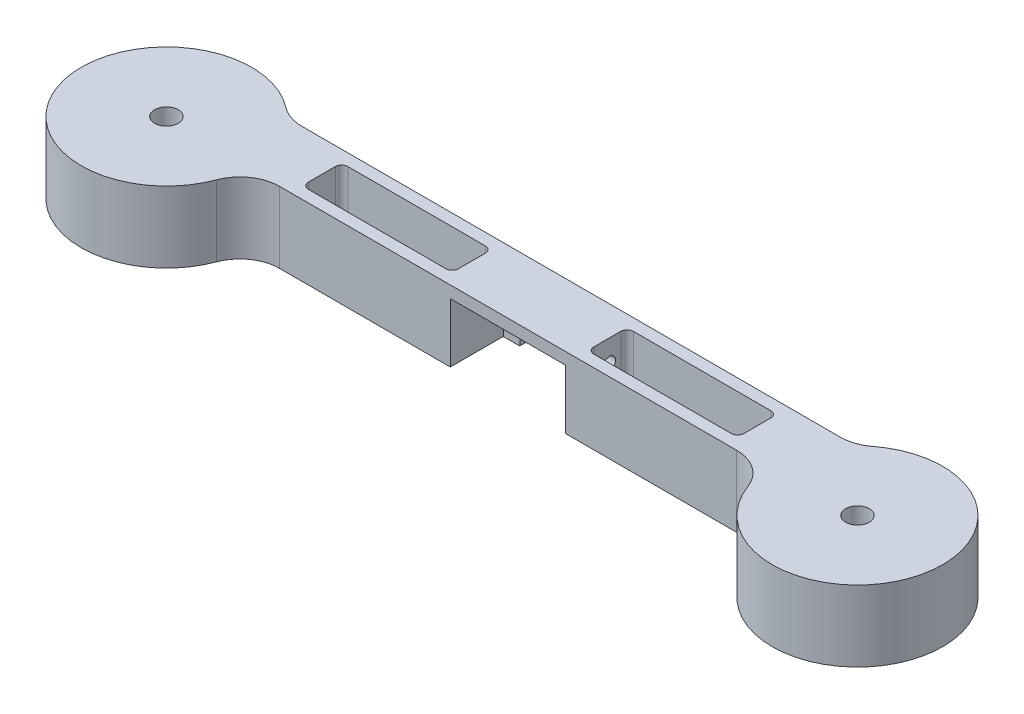
from build123d import *

# Parameters (mm, degrees)
SKETCH1_R      = 3
EXTRUDE1_DEPTH = 18
SKETCH1_3_R    = 19.05
EXTRUDE2_DEPTH = 10
SKETCH2_R      = 1.52
EXTRUDE3_DEPTH = 37.59
EXTRUDE4_START = -2.6
SKETCH3_W      = 29.21
SKETCH3_H      = 15
EXTRUDE4_DEPTH = 34.99
EXTRUDE6_DEPTH = 10
SKETCH8_R      = 1.53
EXTRUDE7_DEPTH = 43
EXTRUDE8_DEPTH = 37.59


with BuildPart() as part:
    # Sketch1 → Extrude1 (new body)
    with BuildSketch(Plane(origin=(0, 0, 0), x_dir=(1, 0, 0), z_dir=(0, 1, 0))):
        with BuildLine():
            Line((-10.033035154, 21.134136258), (126.344272034, 21.134136258))
            ThreePointArc((126.344272034, 21.134136258), (129.573902971, 21.670020662), (132.457392138, 23.220239455))
            ThreePointArc((132.457392138, 23.220239455), (166.412495407, 0.194425945), (125.416806741, -1.383749149))
            ThreePointArc((125.416806741, -1.383749149), (121.751361628, 3.344530461), (116.04264662, 5.134136258))
            Line((116.04264662, 5.134136258), (0.26859026, 5.134136258))
            ThreePointArc((0.26859026, 5.134136258), (-5.440124747, 3.344530461), (-9.10556986, -1.383749149))
            ThreePointArc((-9.10556986, -1.383749149), (-50.101258526, 0.194425945), (-16.146155257, 23.220239455))
            ThreePointArc((-16.146155257, 23.220239455), (-13.262666091, 21.670020662), (-10.033035154, 21.134136258))
        make_face()
        with Locations((-29.34438156, 6.134136258)):
            Circle(SKETCH1_R, mode=Mode.SUBTRACT)
        with Locations((145.65561844, 6.134136258)):
            Circle(SKETCH1_R, mode=Mode.SUBTRACT)
    extrude(amount=EXTRUDE1_DEPTH)

    # Sketch1_3 → Extrude2 (cut)
    with BuildSketch(Plane(origin=(0, 0, 0), x_dir=(1, 0, 0), z_dir=(0, 1, 0))):
        with Locations((-29.34438156, 6.134136258)):
            Circle(SKETCH1_3_R)
        with Locations((145.65561844, 6.134136258)):
            Circle(SKETCH1_3_R)
    extrude(amount=EXTRUDE2_DEPTH, mode=Mode.SUBTRACT)

    # Sketch2 → Extrude3 (cut, through all)
    with BuildSketch(Plane(origin=(0, 0, -21.134136258), x_dir=(-1, 0, 0), z_dir=(0, 0, -1))):
        with Locations((-68.542401875, 7.04)):
            Circle(SKETCH2_R)
        with Locations((-47.61061844, 7.04)):
            Circle(SKETCH2_R)
    extrude(amount=-EXTRUDE3_DEPTH, mode=Mode.SUBTRACT)

    # Sketch3 → Extrude4 (cut, through all)
    with BuildSketch(Plane(origin=(0, 0, -21.134136258), x_dir=(-1, 0, 0), z_dir=(0, 0, -1)).offset(EXTRUDE4_START)):
        with Locations((-58.15561844, 7.5)):
            Rectangle(SKETCH3_W, SKETCH3_H)
    extrude(amount=-EXTRUDE4_DEPTH, mode=Mode.SUBTRACT)

    # Sketch6 → Extrude6 (cut)
    with BuildSketch(Plane(origin=(0, 18, 0), x_dir=(1, 0, 0), z_dir=(0, 1, 0))):
        with BuildLine():
            Line((41.01061844, 13.134136258), (41.01061844, 16.546636258))
            ThreePointArc((41.01061844, 16.546636258), (40.545650455, 17.669168273), (39.42311844, 18.134136258))
            Line((39.42311844, 18.134136258), (4.59811844, 18.134136258))
            ThreePointArc((4.59811844, 18.134136258), (3.475586425, 17.669168273), (3.01061844, 16.546636258))
            Line((3.01061844, 16.546636258), (3.01061844, 9.721636258))
            ThreePointArc((3.01061844, 9.721636258), (3.475586425, 8.599104243), (4.59811844, 8.134136258))
            Line((4.59811844, 8.134136258), (39.42311844, 8.134136258))
            ThreePointArc((39.42311844, 8.134136258), (40.545650455, 8.599104243), (41.01061844, 9.721636258))
            Line((41.01061844, 9.721636258), (41.01061844, 13.134136258))
        make_face()
        with BuildLine():
            Line((75.30061844, 9.721636258), (75.30061844, 13.134136258))
            Line((75.30061844, 13.134136258), (75.30061844, 16.546636258))
            ThreePointArc((75.30061844, 16.546636258), (75.765586425, 17.669168273), (76.88811844, 18.134136258))
            Line((76.88811844, 18.134136258), (111.71311844, 18.134136258))
            ThreePointArc((111.71311844, 18.134136258), (112.835650455, 17.669168273), (113.30061844, 16.546636258))
            Line((113.30061844, 16.546636258), (113.30061844, 9.721636258))
            ThreePointArc((113.30061844, 9.721636258), (112.835650455, 8.599104243), (111.71311844, 8.134136258))
            Line((111.71311844, 8.134136258), (76.88811844, 8.134136258))
            ThreePointArc((76.88811844, 8.134136258), (75.765586425, 8.599104243), (75.30061844, 9.721636258))
        make_face()
    extrude(amount=-EXTRUDE6_DEPTH, mode=Mode.SUBTRACT)

    # Sketch8 → Extrude7 (cut)
    with BuildSketch(Plane(origin=(75.30061844, 0, 0), x_dir=(0, 0, -1), z_dir=(1, 0, 0))):
        with Locations((13.696636258, 12.37)):
            Circle(SKETCH8_R)
    extrude(amount=-EXTRUDE7_DEPTH, mode=Mode.SUBTRACT)

    # Sketch9 → Extrude8 (cut, through all)
    with BuildSketch(Plane(origin=(0, 0, -21.134136258), x_dir=(-1, 0, 0), z_dir=(0, 0, -1))):
        with BuildLine():
            ThreePointArc((-68.427924828, 0), (-58.131552552, -10.4619369), (-47.724510158, -0.110083234))
            ThreePointArc((-47.724510158, -0.110083234), (-47.724656491, -0.055040839), (-47.725095487, 0))
            Line((-47.725095487, 0), (-68.427924828, 0))
        make_face()
        with BuildLine():
            Line((-68.427924828, 0), (-47.725095487, 0))
            ThreePointArc((-47.725095487, 0), (-58.076510158, 10.241916766), (-68.427924828, 0))
        make_face()
    extrude(amount=-EXTRUDE8_DEPTH, mode=Mode.SUBTRACT)


solid = part.part
